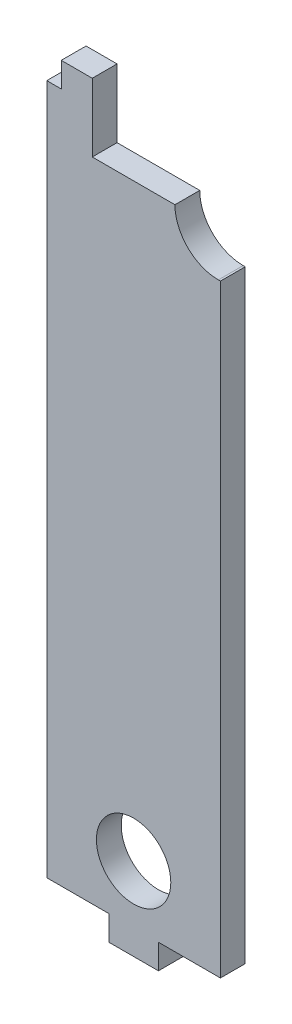
from build123d import *

# Parameters (mm, degrees)
SKETCH1_R           = 9
SKETCH1_W           = 6
SKETCH1_H           = 6
SKETCH1_W_2         = 7.5
BOSS_EXTRUDE1_DEPTH = 6


with BuildPart() as part:
    # Sketch1 → Boss-Extrude1 (new body)
    with BuildSketch(Plane.XY):
        with BuildLine():
            ThreePointArc((20.5, 62.5), (13.075378798, 65.575378798), (10, 73))
            Line((10, 73), (-10, 73))
            Line((-10, 73), (-10, 83.5))
            Line((-10, 83.5), (-17.5, 83.5))
            Line((-17.5, 83.5), (-21, 83.5))
            Line((-21, 83.5), (-21, -83.5))
            Line((-21, -83.5), (-6, -83.5))
            Line((-6, -83.5), (0, -83.5))
            Line((0, -83.5), (6, -83.5))
            Line((6, -83.5), (21, -83.5))
            Line((21, -83.5), (21, 62.5))
            Line((21, 62.5), (20.5, 62.5))
        make_face()
        with Locations((0, -69.5)):
            Circle(SKETCH1_R, mode=Mode.SUBTRACT)
        with Locations((3, -86.5)):
            Rectangle(SKETCH1_W, SKETCH1_H)
        with Locations((-3, -86.5)):
            Rectangle(SKETCH1_W, SKETCH1_H)
        with Locations((-13.75, 86.5)):
            Rectangle(SKETCH1_W_2, SKETCH1_H)
    extrude(amount=-BOSS_EXTRUDE1_DEPTH)


solid = part.part
